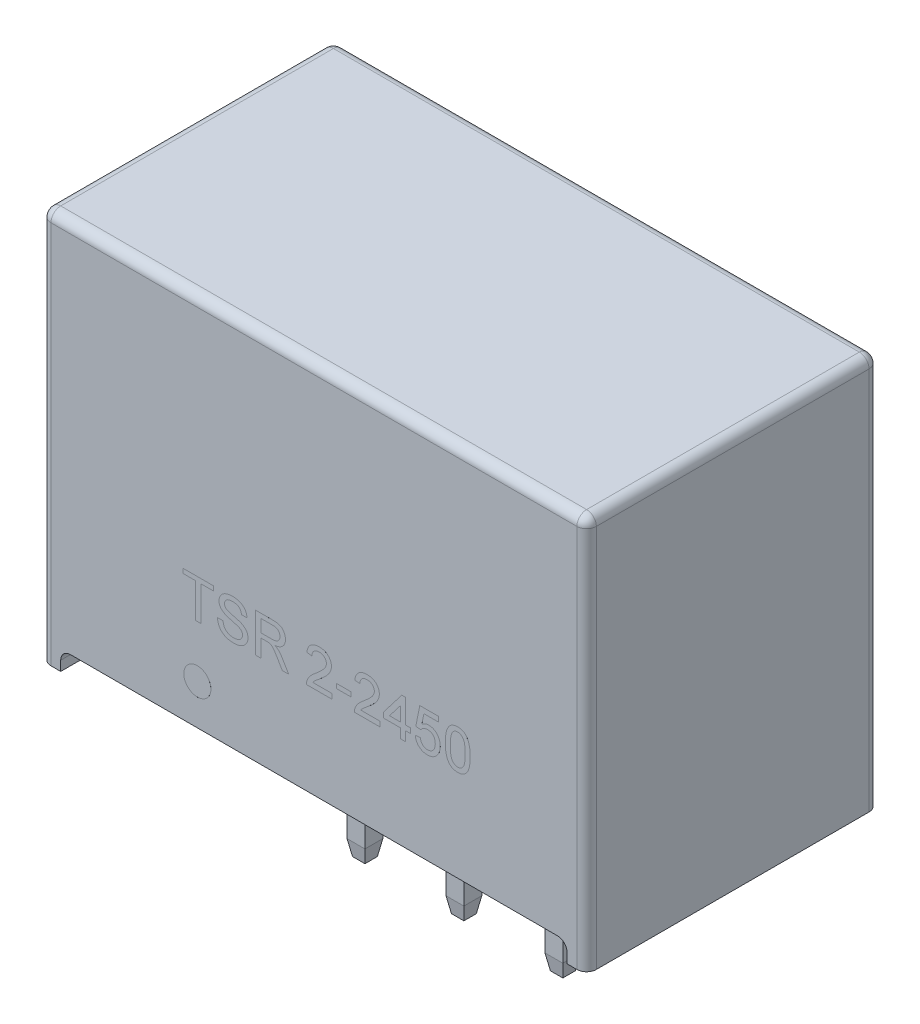
from build123d import *

# Parameters (mm, degrees)
SKETCH2_W              = 14
SKETCH2_H              = 7.5
BOSS_EXTRUDE1_DEPTH    = 10.1
SKETCH3_W              = 13
SKETCH3_H              = 7.5
CUT_EXTRUDE1_DEPTH     = 0.5
SKETCH5_R              = 0.348019795
SKETCH5_W              = 0.371794871
SKETCH5_H              = 0.115384615
BOSS_EXTRUDE4_DEPTH    = 0.0001
SKETCH4_W              = 0.46
SKETCH4_H              = 0.46
BOSS_EXTRUDE3_DEPTH    = 4.6
FILLET1_R              = 0.25
FILLET2_R              = 0.25
CHAMFER2_SIZE          = 0.4
CHAMFER2_SIZE2         = 0.070530792
CHAMFER2_PART_2_SIZE   = 0.4
CHAMFER2_PART_2_SIZE2  = 0.070530792
CHAMFER2_PART_3_SIZE   = 0.4
CHAMFER2_PART_3_SIZE2  = 0.070530792
CHAMFER2_PART_4_SIZE   = 0.4
CHAMFER2_PART_4_SIZE2  = 0.070530792
CHAMFER2_PART_5_SIZE   = 0.4
CHAMFER2_PART_5_SIZE2  = 0.070530792
CHAMFER2_PART_6_SIZE   = 0.4
CHAMFER2_PART_6_SIZE2  = 0.070530792
CHAMFER2_PART_7_SIZE   = 0.4
CHAMFER2_PART_7_SIZE2  = 0.070530792
CHAMFER2_PART_8_SIZE   = 0.4
CHAMFER2_PART_8_SIZE2  = 0.070530792
CHAMFER2_PART_9_SIZE   = 0.4
CHAMFER2_PART_9_SIZE2  = 0.070530792
CHAMFER2_PART_10_SIZE  = 0.4
CHAMFER2_PART_10_SIZE2 = 0.070530792
CHAMFER2_PART_11_SIZE  = 0.4
CHAMFER2_PART_11_SIZE2 = 0.070530792
CHAMFER2_PART_12_SIZE  = 0.4
CHAMFER2_PART_12_SIZE2 = 0.070530792


with BuildPart() as part:
    # Sketch2 → Boss-Extrude1 (new body)
    with BuildSketch(Plane(origin=(0, 0, 0), x_dir=(1, 0, 0), z_dir=(0, 1, 0))):
        Rectangle(SKETCH2_W, SKETCH2_H)
    extrude(amount=BOSS_EXTRUDE1_DEPTH)

    # Sketch3 → Cut-Extrude1 (cut)
    with BuildSketch(Plane.XZ):
        Rectangle(SKETCH3_W, SKETCH3_H)
    extrude(amount=-CUT_EXTRUDE1_DEPTH, mode=Mode.SUBTRACT)

    # Sketch5 → Boss-Extrude4 (add)
    with BuildSketch(Plane.XY.offset(3.75)):
        with Locations((-2.991998919, 1.533519028)):
            Circle(SKETCH5_R)
        Polygon((-3.038553538, 2.864581875), (-3.038553538, 3.74919726), (-3.359066358, 3.74919726), (-3.359066358, 3.864581875), (-2.577015076, 3.864581875), (-2.577015076, 3.74919726), (-2.897527897, 3.74919726), (-2.897527897, 2.864581875), align=None)
        with BuildLine():
            Line((-2.474450974, 3.210735721), (-2.333425333, 3.210735721))
            add(Edge.make_bspline(
                [(-2.333425333, 3.210735721), (-2.331874133, 3.198073558), (-2.328894193, 3.17374886), (-2.320561986, 3.139272263), (-2.309837897, 3.108274264), (-2.296475978, 3.080343465), (-2.278898883, 3.055814755), (-2.257721506, 3.033690232), (-2.232002735, 3.014531735), (-2.202972106, 2.997481929), (-2.170640086, 2.984095134), (-2.136122771, 2.974171282), (-2.099584779, 2.968291321), (-2.074565811, 2.967533125), (-2.061790717, 2.967145978)],
                knots=[0, 0, 0, 0, 3.8245e-05, 7.3471e-05, 0.000106162, 0.000136532, 0.00016599, 0.000196308, 0.000228039, 0.000261882, 0.000297077, 0.00033271, 0.00036943, 0.000407744, 0.000407744, 0.000407744, 0.000407744], degree=3))
            add(Edge.make_bspline(
                [(-2.061790717, 2.967145978), (-2.05048586, 2.967355218), (-2.028443576, 2.967763198), (-1.996556949, 2.972664039), (-1.966551541, 2.97961575), (-1.938985782, 2.990131301), (-1.913961362, 3.002900478), (-1.892230456, 3.018345096), (-1.873677764, 3.035762383), (-1.859149662, 3.0556111), (-1.847736675, 3.076409237), (-1.839364069, 3.097787576), (-1.834376679, 3.119627459), (-1.833741156, 3.134322458), (-1.833425333, 3.141625144)],
                knots=[0, 0, 0, 0, 3.3883e-05, 6.6066e-05, 9.6578e-05, 0.000126119, 0.000154342, 0.000180633, 0.000205853, 0.000230332, 0.000254089, 0.000276857, 0.000299019, 0.000320913, 0.000320913, 0.000320913, 0.000320913], degree=3))
            add(Edge.make_bspline(
                [(-1.833425333, 3.141625144), (-1.833762954, 3.148853859), (-1.834422834, 3.162982372), (-1.838723091, 3.183551721), (-1.846896336, 3.20237865), (-1.857502061, 3.220231587), (-1.872256435, 3.23655423), (-1.890896921, 3.25159409), (-1.913834217, 3.265229372), (-1.930953457, 3.272696847), (-1.939995846, 3.27664117)],
                knots=[0, 0, 0, 0, 2.1694e-05, 4.2401e-05, 6.2602e-05, 8.3009e-05, 0.000104436, 0.000128214, 0.000154632, 0.000184209, 0.000184209, 0.000184209, 0.000184209], degree=3))
            add(Edge.make_bspline(
                [(-1.939995846, 3.27664117), (-1.943518894, 3.278086913), (-1.951478099, 3.281353108), (-1.965119805, 3.285676988), (-1.981307415, 3.291268207), (-2.000429826, 3.297026252), (-2.022384666, 3.303117458), (-2.047135383, 3.31001178), (-2.074668146, 3.317343514), (-2.104202079, 3.325147347), (-2.134022351, 3.333082647), (-2.162512137, 3.341025379), (-2.188724095, 3.34908827), (-2.212872935, 3.35685172), (-2.234834161, 3.3646472), (-2.254670101, 3.372261286), (-2.272405488, 3.379539498), (-2.283237587, 3.384891056), (-2.288353217, 3.387418413)],
                knots=[0, 0, 0, 0, 1.142e-05, 2.58e-05, 4.2904e-05, 6.2801e-05, 8.5695e-05, 0.000111258, 0.000139879, 0.00017117, 0.000202901, 0.000232453, 0.000259891, 0.000285167, 0.000308547, 0.000329789, 0.000348912, 0.000366025, 0.000366025, 0.000366025, 0.000366025], degree=3))
            add(Edge.make_bspline(
                [(-2.288353217, 3.387418413), (-2.300122855, 3.393776711), (-2.322841318, 3.406049879), (-2.353417854, 3.427994339), (-2.379181689, 3.452345778), (-2.400024132, 3.479068887), (-2.416357539, 3.507711713), (-2.427377617, 3.53832295), (-2.43492546, 3.570346946), (-2.435630826, 3.592368464), (-2.435989435, 3.603564247)],
                knots=[0, 0, 0, 0, 4.0103e-05, 7.7409e-05, 0.000112548, 0.000146087, 0.000178736, 0.000210998, 0.000243416, 0.000276942, 0.000276942, 0.000276942, 0.000276942], degree=3))
            add(Edge.make_bspline(
                [(-2.435989435, 3.603564247), (-2.435513489, 3.615961686), (-2.434566837, 3.640620101), (-2.426169507, 3.676804789), (-2.412775605, 3.711624084), (-2.397529277, 3.739267633), (-2.382660738, 3.76017156), (-2.370334607, 3.775226187), (-2.356508439, 3.789142165), (-2.341608034, 3.802113753), (-2.325367031, 3.81394714), (-2.308188371, 3.825128663), (-2.289450282, 3.83473945), (-2.263120482, 3.846971813), (-2.227897553, 3.859186972), (-2.18355629, 3.869830933), (-2.136888568, 3.87609894), (-2.105078752, 3.87696176), (-2.088833987, 3.877402388)],
                knots=[0, 0, 0, 0, 3.7151e-05, 7.3892e-05, 0.000110797, 0.000148816, 0.000168214, 0.000187707, 0.000207113, 0.000226994, 0.000246907, 0.000267356, 0.000288414, 0.000310016, 0.00035443, 0.000399956, 0.000446645, 0.000495372, 0.000495372, 0.000495372, 0.000495372], degree=3))
            add(Edge.make_bspline(
                [(-2.088833987, 3.877402388), (-2.071053012, 3.876994964), (-2.036430028, 3.876201631), (-1.986121853, 3.869601247), (-1.939198099, 3.85826665), (-1.902398881, 3.845578706), (-1.875193649, 3.832733884), (-1.855866295, 3.8227112), (-1.837926689, 3.811123152), (-1.821213337, 3.79858307), (-1.805570996, 3.785096683), (-1.791401709, 3.770343194), (-1.778090206, 3.754825964), (-1.762447335, 3.732548084), (-1.745581003, 3.703063436), (-1.730997764, 3.664864903), (-1.720978908, 3.624549488), (-1.71903001, 3.59667841), (-1.718040717, 3.582530593)],
                knots=[0, 0, 0, 0, 5.3331e-05, 0.000103845, 0.000151849, 0.000197974, 0.00022029, 0.000242066, 0.000263238, 0.000284271, 0.000304718, 0.000325117, 0.000345585, 0.000365984, 0.000406708, 0.000447108, 0.00048831, 0.000530786, 0.000530786, 0.000530786, 0.000530786], degree=3))
            Line((-1.718040717, 3.582530593), (-1.859066358, 3.582530593))
            add(Edge.make_bspline(
                [(-1.859066358, 3.582530593), (-1.859962415, 3.589691217), (-1.861715731, 3.603702435), (-1.866065476, 3.623985782), (-1.872162943, 3.642824042), (-1.879304946, 3.660392895), (-1.887962548, 3.676509604), (-1.898054808, 3.691328926), (-1.909704626, 3.704676265), (-1.922612242, 3.716904306), (-1.937170431, 3.727551517), (-1.953304389, 3.736793623), (-1.971041351, 3.744601087), (-1.99036569, 3.750995654), (-2.011281232, 3.755953751), (-2.03383555, 3.759601022), (-2.058019926, 3.761468953), (-2.074675329, 3.76183161), (-2.083225012, 3.762017772)],
                knots=[0, 0, 0, 0, 2.1644e-05, 4.2351e-05, 6.2117e-05, 8.0978e-05, 9.9171e-05, 0.000116896, 0.000134648, 0.000152221, 0.000170131, 0.000188617, 0.000207899, 0.00022817, 0.000249596, 0.00027232, 0.000296642, 0.000322295, 0.000322295, 0.000322295, 0.000322295], degree=3))
            add(Edge.make_bspline(
                [(-2.083225012, 3.762017772), (-2.092112009, 3.761950786), (-2.10931505, 3.761821118), (-2.134183996, 3.759457425), (-2.157234295, 3.756214355), (-2.178426355, 3.751430551), (-2.197690753, 3.745168535), (-2.215313401, 3.737937343), (-2.230801111, 3.728773535), (-2.244514927, 3.718566244), (-2.25634483, 3.707272441), (-2.266540455, 3.695371503), (-2.275557697, 3.683213089), (-2.282564293, 3.67013261), (-2.288268716, 3.656625446), (-2.291948695, 3.642437705), (-2.294554206, 3.627831824), (-2.294825378, 3.617865939), (-2.294963794, 3.61277899)],
                knots=[0, 0, 0, 0, 2.6649e-05, 5.1587e-05, 7.4874e-05, 9.645e-05, 0.000116659, 0.000135597, 0.000153463, 0.00017049, 0.000186785, 0.000202407, 0.000217474, 0.000232087, 0.000246818, 0.000261348, 0.00027597, 0.000291215, 0.000291215, 0.000291215, 0.000291215], degree=3))
            add(Edge.make_bspline(
                [(-2.294963794, 3.61277899), (-2.294599351, 3.60417543), (-2.293892, 3.587476712), (-2.28666891, 3.563752868), (-2.275559748, 3.542127048), (-2.264615454, 3.530360549), (-2.259106422, 3.524437644)],
                knots=[0, 0, 0, 0, 2.5736e-05, 4.995e-05, 7.3788e-05, 9.795e-05, 9.795e-05, 9.795e-05, 9.795e-05], degree=3))
            add(Edge.make_bspline(
                [(-2.259106422, 3.524437644), (-2.255633588, 3.52147766), (-2.247953628, 3.514931837), (-2.23366388, 3.506269208), (-2.215946711, 3.497516725), (-2.194683738, 3.488816079), (-2.169911546, 3.480061646), (-2.141670091, 3.471047881), (-2.109851807, 3.462095527), (-2.075426353, 3.453468452), (-2.040648618, 3.444806696), (-2.007598078, 3.436177953), (-1.977252087, 3.428000278), (-1.949658793, 3.420024297), (-1.924789634, 3.41227256), (-1.902731041, 3.404582661), (-1.883304551, 3.397509905), (-1.871403531, 3.392533643), (-1.865877256, 3.390222901)],
                knots=[0, 0, 0, 0, 1.3672e-05, 3.0234e-05, 4.9943e-05, 7.2934e-05, 9.9102e-05, 0.000128751, 0.000161853, 0.000198244, 0.000235217, 0.000269374, 0.000300717, 0.000329499, 0.000355539, 0.000378852, 0.000399578, 0.000417545, 0.000417545, 0.000417545, 0.000417545], degree=3))
            add(Edge.make_bspline(
                [(-1.865877256, 3.390222901), (-1.858687291, 3.386907865), (-1.844574596, 3.380401007), (-1.824582073, 3.369291524), (-1.805926881, 3.357754924), (-1.78875974, 3.345480604), (-1.77313616, 3.332442743), (-1.758881451, 3.318790727), (-1.74590952, 3.304601284), (-1.734743784, 3.289420267), (-1.724718098, 3.273861362), (-1.715944955, 3.257707114), (-1.708880989, 3.240862522), (-1.70268545, 3.223530633), (-1.69822908, 3.205518664), (-1.694734388, 3.18700855), (-1.692695992, 3.167913287), (-1.692499312, 3.154984584), (-1.692399692, 3.148436042)],
                knots=[0, 0, 0, 0, 2.3745e-05, 4.6607e-05, 6.8562e-05, 8.9521e-05, 0.00010986, 0.000129553, 0.000148702, 0.000167452, 0.000186011, 0.000204205, 0.000222512, 0.000240758, 0.000259366, 0.000278108, 0.000297243, 0.000316884, 0.000316884, 0.000316884, 0.000316884], degree=3))
            add(Edge.make_bspline(
                [(-1.692399692, 3.148436042), (-1.692921573, 3.135366931), (-1.69395768, 3.109420403), (-1.702878938, 3.07117402), (-1.716893763, 3.034113488), (-1.733329616, 3.004703915), (-1.748866465, 2.982239275), (-1.761918151, 2.966092719), (-1.776391721, 2.951162767), (-1.791930849, 2.936981692), (-1.808656183, 2.923838835), (-1.826708728, 2.911729721), (-1.845897946, 2.900528294), (-1.873299668, 2.886878699), (-1.909693707, 2.872599927), (-1.956052406, 2.86070905), (-2.00490886, 2.852995143), (-2.038456717, 2.852178306), (-2.055580781, 2.851761362)],
                knots=[0, 0, 0, 0, 3.9163e-05, 7.7752e-05, 0.000117188, 0.000157717, 0.000178444, 0.000199092, 0.000219919, 0.000240765, 0.000262164, 0.000283666, 0.000305929, 0.000328774, 0.000375459, 0.000422881, 0.00047212, 0.000523458, 0.000523458, 0.000523458, 0.000523458], degree=3))
            add(Edge.make_bspline(
                [(-2.055580781, 2.851761362), (-2.066468617, 2.851851214), (-2.087796332, 2.85202722), (-2.119135026, 2.854158708), (-2.14916747, 2.857242011), (-2.17786419, 2.861834625), (-2.205135197, 2.867859885), (-2.23107838, 2.875095058), (-2.255755234, 2.883427852), (-2.279079535, 2.893227072), (-2.300990398, 2.904612696), (-2.321881803, 2.916894904), (-2.341412265, 2.930817362), (-2.359622898, 2.946161299), (-2.376975121, 2.962483445), (-2.392749737, 2.98045038), (-2.407483041, 2.999536689), (-2.420838382, 3.019917055), (-2.432769346, 3.041324835), (-2.443498682, 3.063400511), (-2.452538298, 3.086304222), (-2.459823368, 3.109920215), (-2.465994191, 3.13409045), (-2.470273515, 3.159016587), (-2.473419817, 3.184620366), (-2.474105225, 3.201979185), (-2.474450974, 3.210735721)],
                knots=[0, 0, 0, 0, 3.2658e-05, 6.3972e-05, 9.419e-05, 0.000123204, 0.000151103, 0.000177932, 0.000203968, 0.000229193, 0.000253741, 0.000277996, 0.000301842, 0.000325592, 0.000349396, 0.000373235, 0.000397235, 0.000421681, 0.000446255, 0.000470715, 0.000495266, 0.000520039, 0.000544817, 0.000570045, 0.000595861, 0.000622141, 0.000622141, 0.000622141, 0.000622141], degree=3))
        make_face()
        with BuildLine():
            Line((-1.500091999, 2.864581875), (-1.500091999, 3.864581875))
            Line((-1.500091999, 3.864581875), (-1.066197769, 3.864581875))
            add(Edge.make_bspline(
                [(-1.066197769, 3.864581875), (-1.055980888, 3.864501822), (-1.036207312, 3.864346887), (-1.007531543, 3.86325013), (-0.980765588, 3.860885807), (-0.955860232, 3.858329122), (-0.932819901, 3.854404952), (-0.911668365, 3.849904018), (-0.892372966, 3.844547838), (-0.874847444, 3.838221777), (-0.85858758, 3.831064786), (-0.843515915, 3.822234215), (-0.829005938, 3.812557792), (-0.815596166, 3.80118944), (-0.802932914, 3.788742145), (-0.791027919, 3.775046778), (-0.780057425, 3.759984488), (-0.766526634, 3.738427229), (-0.752010855, 3.709717499), (-0.73991693, 3.672975265), (-0.732118984, 3.634541547), (-0.731284582, 3.608276554), (-0.73086123, 3.594950465)],
                knots=[0, 0, 0, 0, 3.0652e-05, 5.9323e-05, 8.6056e-05, 0.000111253, 0.000134404, 0.000156133, 0.000176109, 0.000194422, 0.000211996, 0.000229314, 0.00024676, 0.000264252, 0.000281959, 0.000299993, 0.000318624, 0.000337798, 0.00037632, 0.000414772, 0.000453548, 0.000493484, 0.000493484, 0.000493484, 0.000493484], degree=3))
            add(Edge.make_bspline(
                [(-0.73086123, 3.594950465), (-0.731056913, 3.586396304), (-0.731443399, 3.56950125), (-0.734403926, 3.544660998), (-0.739760759, 3.520927137), (-0.746629842, 3.498091808), (-0.756031521, 3.476478553), (-0.766922957, 3.455645914), (-0.780415899, 3.436166219), (-0.79552274, 3.417520755), (-0.812846234, 3.400108858), (-0.832538778, 3.384558707), (-0.854405163, 3.370571314), (-0.878548371, 3.358532599), (-0.904690489, 3.347528641), (-0.93315953, 3.338667725), (-0.963840594, 3.331432106), (-0.985110134, 3.327928341), (-0.996085589, 3.326120337)],
                knots=[0, 0, 0, 0, 2.5661e-05, 5.0681e-05, 7.4886e-05, 9.8583e-05, 0.000122099, 0.000145489, 0.000168992, 0.000193051, 0.000217414, 0.000242505, 0.000268178, 0.000295144, 0.000323343, 0.000353183, 0.000384474, 0.000417836, 0.000417836, 0.000417836, 0.000417836], degree=3))
            add(Edge.make_bspline(
                [(-0.996085589, 3.326120337), (-0.988034677, 3.322053193), (-0.972745704, 3.314329542), (-0.951577932, 3.302218923), (-0.933634745, 3.289844855), (-0.923239347, 3.280994558), (-0.91836123, 3.27684149)],
                knots=[0, 0, 0, 0, 2.7057e-05, 5.1383e-05, 7.3111e-05, 9.2322e-05, 9.2322e-05, 9.2322e-05, 9.2322e-05], degree=3))
            add(Edge.make_bspline(
                [(-0.91836123, 3.27684149), (-0.908914481, 3.267580916), (-0.889510187, 3.248559037), (-0.862770227, 3.216159206), (-0.836844918, 3.180093222), (-0.821093338, 3.154028213), (-0.81299264, 3.140623542)],
                knots=[0, 0, 0, 0, 3.9662e-05, 8.1469e-05, 0.000125831, 0.0001728, 0.0001728, 0.0001728, 0.0001728], degree=3))
            Line((-0.81299264, 3.140623542), (-0.64893014, 2.864581875))
            Line((-0.64893014, 2.864581875), (-0.810588794, 2.864581875))
            Line((-0.810588794, 2.864581875), (-0.935188153, 3.075719696))
            add(Edge.make_bspline(
                [(-0.935188153, 3.075719696), (-0.93966812, 3.08312772), (-0.948349561, 3.097483254), (-0.960889591, 3.118448821), (-0.973184678, 3.137750967), (-0.984588161, 3.155941355), (-0.995562812, 3.17268975), (-1.006002591, 3.188054332), (-1.01562019, 3.202236664), (-1.02753283, 3.218748589), (-1.041397164, 3.237019188), (-1.05757589, 3.255834454), (-1.072982835, 3.270835615), (-1.091956772, 3.28554585), (-1.115458862, 3.299304801), (-1.135436083, 3.305626661), (-1.145124051, 3.308692452)],
                knots=[0, 0, 0, 0, 2.5972e-05, 5.033e-05, 7.3284e-05, 9.4624e-05, 0.000114737, 0.00013335, 0.000150352, 0.000166141, 0.000194428, 0.000219133, 0.000240526, 0.000258798, 0.000291099, 0.000321512, 0.000321512, 0.000321512, 0.000321512], degree=3))
            add(Edge.make_bspline(
                [(-1.145124051, 3.308692452), (-1.149188763, 3.309425458), (-1.158468622, 3.311098932), (-1.1742258, 3.31219188), (-1.193317555, 3.313351899), (-1.207153674, 3.3133181), (-1.214635269, 3.313299824)],
                knots=[0, 0, 0, 0, 1.2383e-05, 2.827e-05, 4.7327e-05, 6.9764e-05, 6.9764e-05, 6.9764e-05, 6.9764e-05], degree=3))
            Line((-1.214635269, 3.313299824), (-1.359066358, 3.313299824))
            Line((-1.359066358, 3.313299824), (-1.359066358, 2.864581875))
            Line((-1.359066358, 2.864581875), (-1.500091999, 2.864581875))
        make_face()
        with BuildLine():
            Line((-1.359066358, 3.428684439), (-1.091237833, 3.428684439))
            add(Edge.make_bspline(
                [(-1.091237833, 3.428684439), (-1.077807896, 3.428894563), (-1.052701889, 3.429287371), (-1.01759511, 3.432641532), (-0.987676322, 3.437971437), (-0.962354076, 3.445745727), (-0.941079391, 3.456539024), (-0.922576394, 3.469692673), (-0.90720017, 3.486168988), (-0.894408741, 3.504759002), (-0.8844657, 3.525216384), (-0.877293265, 3.546703864), (-0.872598781, 3.569040854), (-0.872126276, 3.584243101), (-0.871886871, 3.591945657)],
                knots=[0, 0, 0, 0, 4.0282e-05, 7.5304e-05, 0.000105674, 0.000131332, 0.000154445, 0.000176964, 0.000199068, 0.000221683, 0.000244439, 0.000267054, 0.000289525, 0.000312605, 0.000312605, 0.000312605, 0.000312605], degree=3))
            add(Edge.make_bspline(
                [(-0.871886871, 3.591945657), (-0.872072999, 3.597558803), (-0.872437568, 3.608553306), (-0.874348758, 3.624690184), (-0.878064567, 3.640023949), (-0.882971284, 3.654635655), (-0.889527653, 3.668418283), (-0.897316351, 3.681478633), (-0.906610673, 3.693744319), (-0.917256784, 3.705252704), (-0.929480455, 3.71572421), (-0.94344276, 3.724758848), (-0.95903358, 3.732436341), (-0.976271037, 3.738529714), (-0.99510083, 3.743403419), (-1.015630152, 3.746645739), (-1.037765119, 3.74899187), (-1.053103367, 3.749127517), (-1.060989435, 3.74919726)],
                knots=[0, 0, 0, 0, 1.6846e-05, 3.2996e-05, 4.8642e-05, 6.4099e-05, 7.9154e-05, 9.4339e-05, 0.000109643, 0.000125235, 0.000141292, 0.000157793, 0.000174994, 0.000193307, 0.000212547, 0.000233261, 0.000255606, 0.000279251, 0.000279251, 0.000279251, 0.000279251], degree=3))
            Line((-1.060989435, 3.74919726), (-1.359066358, 3.74919726))
            Line((-1.359066358, 3.74919726), (-1.359066358, 3.428684439))
        make_face(mode=Mode.SUBTRACT)
        with BuildLine():
            Line((0.461446462, 2.992787003), (0.461446462, 2.864581875))
            Line((0.461446462, 2.864581875), (-0.192399692, 2.864581875))
            add(Edge.make_bspline(
                [(-0.192399692, 2.864581875), (-0.192413078, 2.872201466), (-0.192439805, 2.887415109), (-0.189865411, 2.909915123), (-0.185833396, 2.932116654), (-0.181274397, 2.946353614), (-0.178978217, 2.953524183)],
                knots=[0, 0, 0, 0, 2.284e-05, 4.5604e-05, 6.784e-05, 9.0404e-05, 9.0404e-05, 9.0404e-05, 9.0404e-05], degree=3))
            add(Edge.make_bspline(
                [(-0.178978217, 2.953524183), (-0.174735642, 2.965240037), (-0.166097059, 2.989095445), (-0.148595199, 3.023515468), (-0.128008876, 3.057727326), (-0.107965193, 3.085580608), (-0.089609507, 3.107833433), (-0.074215872, 3.125243694), (-0.057156903, 3.143065147), (-0.03844626, 3.161294538), (-0.018264024, 3.18004993), (0.003417345, 3.199393873), (0.02685387, 3.218965871), (0.043215018, 3.231939005), (0.051590693, 3.238580272)],
                knots=[0, 0, 0, 0, 3.7351e-05, 7.6052e-05, 0.000115594, 0.000157068, 0.000178844, 0.000202118, 0.000226771, 0.000252836, 0.000280475, 0.000309421, 0.000339994, 0.000372061, 0.000372061, 0.000372061, 0.000372061], degree=3))
            add(Edge.make_bspline(
                [(0.051590693, 3.238580272), (0.064457799, 3.249410307), (0.089234227, 3.270264224), (0.124222427, 3.301209505), (0.156178452, 3.329943952), (0.18459344, 3.356971193), (0.209699794, 3.382029083), (0.231556465, 3.405060849), (0.250351515, 3.425994614), (0.265855493, 3.445588092), (0.278936675, 3.464089785), (0.290021821, 3.482137044), (0.29925982, 3.500045115), (0.306953836, 3.517757332), (0.31303915, 3.53534944), (0.317187157, 3.552872694), (0.320000191, 3.570153219), (0.320281638, 3.581651872), (0.320420821, 3.587338285)],
                knots=[0, 0, 0, 0, 5.0453e-05, 9.715e-05, 0.000140121, 0.00017937, 0.000214782, 0.000246523, 0.000274621, 0.000299148, 0.000321434, 0.000342563, 0.000362632, 0.000381834, 0.000400458, 0.000418387, 0.00043581, 0.000452856, 0.000452856, 0.000452856, 0.000452856], degree=3))
            add(Edge.make_bspline(
                [(0.320420821, 3.587338285), (0.320281621, 3.59295835), (0.320008518, 3.603984613), (0.317417331, 3.620121478), (0.313810192, 3.635661666), (0.307978544, 3.650325417), (0.301037129, 3.664546983), (0.292133088, 3.677876981), (0.281832943, 3.690647627), (0.270040148, 3.702522221), (0.257159655, 3.713662486), (0.24276754, 3.722922752), (0.227809072, 3.731259751), (0.211768198, 3.737963176), (0.194670982, 3.742885621), (0.176641885, 3.746458048), (0.157683767, 3.748723159), (0.144746185, 3.74903683), (0.138129154, 3.74919726)],
                knots=[0, 0, 0, 0, 1.6846e-05, 3.3051e-05, 4.8938e-05, 6.46e-05, 8.0278e-05, 9.6335e-05, 0.000112572, 0.000129429, 0.000146485, 0.000163542, 0.000180664, 0.000197815, 0.000215563, 0.000233949, 0.000252908, 0.000272756, 0.000272756, 0.000272756, 0.000272756], degree=3))
            add(Edge.make_bspline(
                [(0.138129154, 3.74919726), (0.131178148, 3.749037624), (0.117574517, 3.748725207), (0.097689653, 3.746451063), (0.078812421, 3.742976478), (0.060987878, 3.737664136), (0.044237719, 3.730971889), (0.028630165, 3.722548132), (0.013915272, 3.713039234), (0.00055647, 3.701781417), (-0.011523719, 3.689298794), (-0.022248115, 3.675708993), (-0.031035146, 3.66074976), (-0.038291839, 3.644750014), (-0.044126827, 3.627659459), (-0.04836283, 3.60934744), (-0.050672327, 3.589866832), (-0.051136748, 3.576526516), (-0.051374051, 3.56971008)],
                knots=[0, 0, 0, 0, 2.0849e-05, 4.0803e-05, 5.9975e-05, 7.8356e-05, 9.6509e-05, 0.000113984, 0.000131486, 0.000148978, 0.000166261, 0.000183532, 0.000200778, 0.000218169, 0.00023616, 0.000254868, 0.000274448, 0.000294905, 0.000294905, 0.000294905, 0.000294905], degree=3))
            Line((-0.051374051, 3.56971008), (-0.179579179, 3.582530593))
            add(Edge.make_bspline(
                [(-0.179579179, 3.582530593), (-0.178267458, 3.593703983), (-0.175715619, 3.615440852), (-0.169359335, 3.646923045), (-0.160435687, 3.676210509), (-0.14975779, 3.703711573), (-0.136372039, 3.728958085), (-0.1212406, 3.752472242), (-0.103393766, 3.773508272), (-0.083677749, 3.792729262), (-0.06187654, 3.809668012), (-0.038194925, 3.824466362), (-0.012643739, 3.836844268), (0.014634707, 3.847092658), (0.043703039, 3.85486837), (0.074520135, 3.860444288), (0.107135552, 3.863881348), (0.129506864, 3.864345034), (0.140933642, 3.864581875)],
                knots=[0, 0, 0, 0, 3.3743e-05, 6.5643e-05, 9.6189e-05, 0.000125502, 0.000153995, 0.000181776, 0.00020922, 0.000236561, 0.00026425, 0.000291876, 0.000320186, 0.000349282, 0.000379168, 0.000410326, 0.000443155, 0.000477431, 0.000477431, 0.000477431, 0.000477431], degree=3))
            add(Edge.make_bspline(
                [(0.140933642, 3.864581875), (0.152497191, 3.864383862), (0.175023053, 3.863998133), (0.207846856, 3.860051342), (0.23881702, 3.853904251), (0.268047083, 3.845337089), (0.295364348, 3.834102984), (0.32078983, 3.820377445), (0.344440759, 3.804294359), (0.365921978, 3.785660662), (0.385292154, 3.765318859), (0.402267257, 3.74360977), (0.416459261, 3.720626137), (0.428542871, 3.696681243), (0.43750573, 3.671269147), (0.443808578, 3.644735332), (0.448091546, 3.617057124), (0.448445447, 3.59817222), (0.448625949, 3.588540208)],
                knots=[0, 0, 0, 0, 3.4676e-05, 6.755e-05, 9.9018e-05, 0.000129315, 0.000158777, 0.000187459, 0.000215851, 0.000244402, 0.000272599, 0.000300007, 0.00032691, 0.000353517, 0.000380319, 0.000407527, 0.000435262, 0.000464133, 0.000464133, 0.000464133, 0.000464133], degree=3))
            add(Edge.make_bspline(
                [(0.448625949, 3.588540208), (0.448350325, 3.578644408), (0.447798467, 3.558830969), (0.443491146, 3.529215721), (0.436121271, 3.499921865), (0.426350784, 3.470592876), (0.413002265, 3.441112349), (0.396138678, 3.4110736), (0.375217555, 3.380365667), (0.355097301, 3.354260513), (0.336368611, 3.33237781), (0.319767396, 3.314367068), (0.300560752, 3.295231858), (0.27946919, 3.274309485), (0.255632497, 3.252342527), (0.229735555, 3.228673171), (0.201211469, 3.203924304), (0.181410194, 3.187017066), (0.171182039, 3.178283798)],
                knots=[0, 0, 0, 0, 2.9681e-05, 5.9427e-05, 8.9549e-05, 0.00012021, 0.000152041, 0.00018648, 0.000223427, 0.000263415, 0.000285295, 0.00030982, 0.000336875, 0.000366622, 0.000398938, 0.000434108, 0.000471872, 0.000512221, 0.000512221, 0.000512221, 0.000512221], degree=3))
            add(Edge.make_bspline(
                [(0.171182039, 3.178283798), (0.162423169, 3.171153144), (0.145721353, 3.157556085), (0.121959783, 3.137844065), (0.100676644, 3.119768676), (0.081374233, 3.103919503), (0.06475553, 3.089529943), (0.050235166, 3.077230195), (0.038340673, 3.066401832), (0.020227466, 3.049953331), (-0.002714457, 3.026507654), (-0.019619046, 3.003726145), (-0.02773623, 2.992787003)],
                knots=[0, 0, 0, 0, 3.3883e-05, 6.461e-05, 9.2618e-05, 0.000117651, 0.000139531, 0.000158565, 0.000174735, 0.000187779, 0.000231981, 0.000272812, 0.000272812, 0.000272812, 0.000272812], degree=3))
            Line((-0.02773623, 2.992787003), (0.461446462, 2.992787003))
        make_face()
        with Locations((0.762728514, 3.217145978)):
            Rectangle(SKETCH5_W, SKETCH5_H)
        with BuildLine():
            Line((1.692215693, 2.992787003), (1.692215693, 2.864581875))
            Line((1.692215693, 2.864581875), (1.038369539, 2.864581875))
            add(Edge.make_bspline(
                [(1.038369539, 2.864581875), (1.038356153, 2.872201466), (1.038329426, 2.887415109), (1.04090382, 2.909915123), (1.044935835, 2.932116654), (1.049494834, 2.946353614), (1.051791013, 2.953524183)],
                knots=[0, 0, 0, 0, 2.284e-05, 4.5604e-05, 6.784e-05, 9.0404e-05, 9.0404e-05, 9.0404e-05, 9.0404e-05], degree=3))
            add(Edge.make_bspline(
                [(1.051791013, 2.953524183), (1.056033589, 2.965240037), (1.064672172, 2.989095445), (1.082174032, 3.023515468), (1.102760355, 3.057727326), (1.122804038, 3.085580608), (1.141159724, 3.107833433), (1.156553359, 3.125243694), (1.173612328, 3.143065147), (1.19232297, 3.161294538), (1.212505207, 3.18004993), (1.234186576, 3.199393873), (1.257623101, 3.218965871), (1.273984249, 3.231939005), (1.282359924, 3.238580272)],
                knots=[0, 0, 0, 0, 3.7351e-05, 7.6052e-05, 0.000115594, 0.000157068, 0.000178844, 0.000202118, 0.000226771, 0.000252836, 0.000280475, 0.000309421, 0.000339994, 0.000372061, 0.000372061, 0.000372061, 0.000372061], degree=3))
            add(Edge.make_bspline(
                [(1.282359924, 3.238580272), (1.29522703, 3.249410307), (1.320003458, 3.270264224), (1.354991658, 3.301209505), (1.386947683, 3.329943952), (1.41536267, 3.356971193), (1.440469025, 3.382029083), (1.462325696, 3.405060849), (1.481120746, 3.425994614), (1.496624724, 3.445588092), (1.509705906, 3.464089785), (1.520791052, 3.482137044), (1.53002905, 3.500045115), (1.537723067, 3.517757332), (1.543808381, 3.53534944), (1.547956387, 3.552872694), (1.550769422, 3.570153219), (1.551050869, 3.581651872), (1.551190052, 3.587338285)],
                knots=[0, 0, 0, 0, 5.0453e-05, 9.715e-05, 0.000140121, 0.00017937, 0.000214782, 0.000246523, 0.000274621, 0.000299148, 0.000321434, 0.000342563, 0.000362632, 0.000381834, 0.000400458, 0.000418387, 0.00043581, 0.000452856, 0.000452856, 0.000452856, 0.000452856], degree=3))
            add(Edge.make_bspline(
                [(1.551190052, 3.587338285), (1.551050852, 3.59295835), (1.550777749, 3.603984613), (1.548186562, 3.620121478), (1.544579422, 3.635661666), (1.538747775, 3.650325417), (1.53180636, 3.664546983), (1.522902319, 3.677876981), (1.512602173, 3.690647627), (1.500809379, 3.702522221), (1.487928886, 3.713662486), (1.47353677, 3.722922752), (1.458578303, 3.731259751), (1.442537428, 3.737963176), (1.425440213, 3.742885621), (1.407411116, 3.746458048), (1.388452998, 3.748723159), (1.375515416, 3.74903683), (1.368898385, 3.74919726)],
                knots=[0, 0, 0, 0, 1.6846e-05, 3.3051e-05, 4.8938e-05, 6.46e-05, 8.0278e-05, 9.6335e-05, 0.000112572, 0.000129429, 0.000146485, 0.000163542, 0.000180664, 0.000197815, 0.000215563, 0.000233949, 0.000252908, 0.000272756, 0.000272756, 0.000272756, 0.000272756], degree=3))
            add(Edge.make_bspline(
                [(1.368898385, 3.74919726), (1.361947379, 3.749037624), (1.348343748, 3.748725207), (1.328458883, 3.746451063), (1.309581651, 3.742976478), (1.291757109, 3.737664136), (1.27500695, 3.730971889), (1.259399395, 3.722548132), (1.244684503, 3.713039234), (1.231325701, 3.701781417), (1.219245511, 3.689298794), (1.208521115, 3.675708993), (1.199734084, 3.66074976), (1.192477392, 3.644750014), (1.186642404, 3.627659459), (1.182406401, 3.60934744), (1.180096903, 3.589866832), (1.179632483, 3.576526516), (1.17939518, 3.56971008)],
                knots=[0, 0, 0, 0, 2.0849e-05, 4.0803e-05, 5.9975e-05, 7.8356e-05, 9.6509e-05, 0.000113984, 0.000131486, 0.000148978, 0.000166261, 0.000183532, 0.000200778, 0.000218169, 0.00023616, 0.000254868, 0.000274448, 0.000294905, 0.000294905, 0.000294905, 0.000294905], degree=3))
            Line((1.17939518, 3.56971008), (1.051190052, 3.582530593))
            add(Edge.make_bspline(
                [(1.051190052, 3.582530593), (1.052501772, 3.593703983), (1.055053612, 3.615440852), (1.061409896, 3.646923045), (1.070333544, 3.676210509), (1.081011441, 3.703711573), (1.094397192, 3.728958085), (1.109528631, 3.752472242), (1.127375465, 3.773508272), (1.147091481, 3.792729262), (1.168892691, 3.809668012), (1.192574305, 3.824466362), (1.218125491, 3.836844268), (1.245403938, 3.847092658), (1.27447227, 3.85486837), (1.305289365, 3.860444288), (1.337904783, 3.863881348), (1.360276095, 3.864345034), (1.371702872, 3.864581875)],
                knots=[0, 0, 0, 0, 3.3743e-05, 6.5643e-05, 9.6189e-05, 0.000125502, 0.000153995, 0.000181776, 0.00020922, 0.000236561, 0.00026425, 0.000291876, 0.000320186, 0.000349282, 0.000379168, 0.000410326, 0.000443155, 0.000477431, 0.000477431, 0.000477431, 0.000477431], degree=3))
            add(Edge.make_bspline(
                [(1.371702872, 3.864581875), (1.383266422, 3.864383862), (1.405792284, 3.863998133), (1.438616086, 3.860051342), (1.469586251, 3.853904251), (1.498816313, 3.845337089), (1.526133579, 3.834102984), (1.551559061, 3.820377445), (1.57520999, 3.804294359), (1.596691208, 3.785660662), (1.616061385, 3.765318859), (1.633036488, 3.74360977), (1.647228492, 3.720626137), (1.659312101, 3.696681243), (1.668274961, 3.671269147), (1.674577809, 3.644735332), (1.678860777, 3.617057124), (1.679214677, 3.59817222), (1.67939518, 3.588540208)],
                knots=[0, 0, 0, 0, 3.4676e-05, 6.755e-05, 9.9018e-05, 0.000129315, 0.000158777, 0.000187459, 0.000215851, 0.000244402, 0.000272599, 0.000300007, 0.00032691, 0.000353517, 0.000380319, 0.000407527, 0.000435262, 0.000464133, 0.000464133, 0.000464133, 0.000464133], degree=3))
            add(Edge.make_bspline(
                [(1.67939518, 3.588540208), (1.679119555, 3.578644408), (1.678567698, 3.558830969), (1.674260377, 3.529215721), (1.666890502, 3.499921865), (1.657120015, 3.470592876), (1.643771496, 3.441112349), (1.626907909, 3.4110736), (1.605986786, 3.380365667), (1.585866532, 3.354260513), (1.567137841, 3.33237781), (1.550536627, 3.314367068), (1.531329982, 3.295231858), (1.510238421, 3.274309485), (1.486401728, 3.252342527), (1.460504786, 3.228673171), (1.4319807, 3.203924304), (1.412179425, 3.187017066), (1.40195127, 3.178283798)],
                knots=[0, 0, 0, 0, 2.9681e-05, 5.9427e-05, 8.9549e-05, 0.00012021, 0.000152041, 0.00018648, 0.000223427, 0.000263415, 0.000285295, 0.00030982, 0.000336875, 0.000366622, 0.000398938, 0.000434108, 0.000471872, 0.000512221, 0.000512221, 0.000512221, 0.000512221], degree=3))
            add(Edge.make_bspline(
                [(1.40195127, 3.178283798), (1.3931924, 3.171153144), (1.376490584, 3.157556085), (1.352729014, 3.137844065), (1.331445875, 3.119768676), (1.312143463, 3.103919503), (1.295524761, 3.089529943), (1.281004397, 3.077230195), (1.269109904, 3.066401832), (1.250996696, 3.049953331), (1.228054774, 3.026507654), (1.211150185, 3.003726145), (1.203033001, 2.992787003)],
                knots=[0, 0, 0, 0, 3.3883e-05, 6.461e-05, 9.2618e-05, 0.000117651, 0.000139531, 0.000158565, 0.000174735, 0.000187779, 0.000231981, 0.000272812, 0.000272812, 0.000272812, 0.000272812], degree=3))
            Line((1.203033001, 2.992787003), (1.692215693, 2.992787003))
        make_face()
        Polygon((2.217856719, 2.864581875), (2.217856719, 3.108171619), (1.781959283, 3.108171619), (1.781959283, 3.236376747), (2.256318257, 3.851761362), (2.346061847, 3.851761362), (2.346061847, 3.236376747), (2.474266975, 3.236376747), (2.474266975, 3.108171619), (2.346061847, 3.108171619), (2.346061847, 2.864581875), align=None)
        Polygon((2.217856719, 3.236376747), (2.217856719, 3.596553029), (1.940212488, 3.236376747), align=None, mode=Mode.SUBTRACT)
        with BuildLine():
            Line((2.602472103, 3.133812644), (2.730677231, 3.146633157))
            add(Edge.make_bspline(
                [(2.730677231, 3.146633157), (2.731946663, 3.139409502), (2.734415906, 3.125358369), (2.739121321, 3.105018937), (2.745232316, 3.086123036), (2.752098691, 3.068507017), (2.760260536, 3.052357147), (2.769103963, 3.037418429), (2.779532978, 3.024221139), (2.790497687, 3.012075048), (2.802532293, 3.001372194), (2.815752921, 2.992349319), (2.829790706, 2.984477407), (2.844816624, 2.978032235), (2.860853704, 2.973314708), (2.877697836, 2.969583954), (2.895565919, 2.967704045), (2.90775719, 2.967334379), (2.913970501, 2.967145978)],
                knots=[0, 0, 0, 0, 2.2002e-05, 4.2798e-05, 6.2564e-05, 8.1535e-05, 9.9453e-05, 0.000116802, 0.00013351, 0.000149815, 0.000165852, 0.000181689, 0.000197741, 0.000214075, 0.000230615, 0.000247824, 0.000265764, 0.000284411, 0.000284411, 0.000284411, 0.000284411], degree=3))
            add(Edge.make_bspline(
                [(2.913970501, 2.967145978), (2.921592841, 2.967330155), (2.936498659, 2.967690323), (2.958183802, 2.970736478), (2.978667175, 2.975759235), (2.997850769, 2.982788209), (3.015959474, 2.991529571), (3.032392546, 3.002848042), (3.048046006, 3.015571122), (3.06191255, 3.030739475), (3.074535, 3.047252761), (3.085429124, 3.065277715), (3.094600438, 3.084561343), (3.102321681, 3.105099947), (3.108023256, 3.127010858), (3.112217224, 3.150177513), (3.114909585, 3.17461467), (3.115163128, 3.191364225), (3.115292616, 3.199918413)],
                knots=[0, 0, 0, 0, 2.2858e-05, 4.4701e-05, 6.5544e-05, 8.6013e-05, 0.000105901, 0.00012568, 0.000145737, 0.000166288, 0.000187162, 0.000208016, 0.00022934, 0.000251145, 0.000273739, 0.000297157, 0.000321734, 0.000347388, 0.000347388, 0.000347388, 0.000347388], degree=3))
            add(Edge.make_bspline(
                [(3.115292616, 3.199918413), (3.115145443, 3.208070443), (3.114858862, 3.223944336), (3.112445384, 3.247059363), (3.108373563, 3.268794484), (3.103105008, 3.289389257), (3.095842969, 3.308521864), (3.087229782, 3.326469709), (3.076678267, 3.342851886), (3.064939009, 3.358178477), (3.051531295, 3.371918148), (3.036273988, 3.38351956), (3.019765623, 3.393673138), (3.001673706, 3.401907057), (2.981987582, 3.408024549), (2.960902878, 3.412731409), (2.938200809, 3.415207024), (2.922589412, 3.415641025), (2.914571462, 3.415863926)],
                knots=[0, 0, 0, 0, 2.4452e-05, 4.7614e-05, 6.9617e-05, 9.0753e-05, 0.000111292, 0.000130912, 0.000150362, 0.000169636, 0.000188759, 0.000207751, 0.00022699, 0.000246802, 0.000267201, 0.000288734, 0.000311519, 0.000335578, 0.000335578, 0.000335578, 0.000335578], degree=3))
            add(Edge.make_bspline(
                [(2.914571462, 3.415863926), (2.904601531, 3.415572286), (2.885481459, 3.415012987), (2.858007881, 3.410307801), (2.832997689, 3.402707172), (2.810734046, 3.39137936), (2.790842582, 3.377846428), (2.772910061, 3.362533301), (2.756788612, 3.345450332), (2.747945341, 3.33258884), (2.743497744, 3.326120337)],
                knots=[0, 0, 0, 0, 2.9891e-05, 5.7324e-05, 8.3363e-05, 0.000107999, 0.000131946, 0.00015539, 0.000178636, 0.000202156, 0.000202156, 0.000202156, 0.000202156], degree=3))
            Line((2.743497744, 3.326120337), (2.615292616, 3.338940849))
            Line((2.615292616, 3.338940849), (2.717856719, 3.851761362))
            Line((2.717856719, 3.851761362), (3.192215693, 3.851761362))
            Line((3.192215693, 3.851761362), (3.192215693, 3.723556234))
            Line((3.192215693, 3.723556234), (2.822624347, 3.723556234))
            Line((2.822624347, 3.723556234), (2.771742936, 3.464541811))
            add(Edge.make_bspline(
                [(2.771742936, 3.464541811), (2.778816952, 3.469850251), (2.7927092, 3.480275189), (2.814378616, 3.49392527), (2.836357882, 3.505431379), (2.858519052, 3.514853914), (2.88103816, 3.522194052), (2.903779316, 3.527293641), (2.926819949, 3.530740244), (2.942270053, 3.531078626), (2.950028193, 3.531248542)],
                knots=[0, 0, 0, 0, 2.6525e-05, 5.2091e-05, 7.6731e-05, 0.000100878, 0.000124253, 0.000147676, 0.000170737, 0.000193995, 0.000193995, 0.000193995, 0.000193995], degree=3))
            add(Edge.make_bspline(
                [(2.950028193, 3.531248542), (2.960124886, 3.530984), (2.980007723, 3.530463054), (3.009305772, 3.526182826), (3.037319635, 3.518916855), (3.064269051, 3.509130651), (3.08979866, 3.496157366), (3.114167059, 3.480449473), (3.137275864, 3.461877496), (3.158994434, 3.440791849), (3.178694041, 3.417384565), (3.196325833, 3.392419039), (3.210726517, 3.365395531), (3.22283848, 3.337019629), (3.231973583, 3.306825533), (3.238907444, 3.275241757), (3.24261475, 3.241873433), (3.243198806, 3.219157373), (3.243497744, 3.207530593)],
                knots=[0, 0, 0, 0, 3.0281e-05, 5.963e-05, 8.8588e-05, 0.000116981, 0.000145469, 0.000174308, 0.000203809, 0.000234267, 0.000264969, 0.000295477, 0.000325773, 0.000356653, 0.000387891, 0.000420266, 0.000453538, 0.000488422, 0.000488422, 0.000488422, 0.000488422], degree=3))
            add(Edge.make_bspline(
                [(3.243497744, 3.207530593), (3.243270745, 3.196436734), (3.242822356, 3.174523196), (3.239147717, 3.142229548), (3.233094623, 3.111112076), (3.2249912, 3.081078632), (3.214042388, 3.052299783), (3.200762503, 3.02468257), (3.185443412, 2.997938817), (3.173158296, 2.981452837), (3.166975308, 2.973155593)],
                knots=[0, 0, 0, 0, 3.3275e-05, 6.5727e-05, 9.7353e-05, 0.000128311, 0.000158931, 0.000189574, 0.000220186, 0.000251204, 0.000251204, 0.000251204, 0.000251204], degree=3))
            add(Edge.make_bspline(
                [(3.166975308, 2.973155593), (3.159119996, 2.963470098), (3.143667753, 2.944417688), (3.116912363, 2.919688802), (3.088149939, 2.898672651), (3.057209313, 2.881598552), (3.0242982, 2.867878067), (2.989012294, 2.8587476), (2.951777966, 2.85261613), (2.926215878, 2.852050205), (2.913169219, 2.851761362)],
                knots=[0, 0, 0, 0, 3.7372e-05, 7.3515e-05, 0.000108935, 0.000143996, 0.0001793, 0.000215598, 0.00025311, 0.000292214, 0.000292214, 0.000292214, 0.000292214], degree=3))
            add(Edge.make_bspline(
                [(2.913169219, 2.851761362), (2.902407795, 2.851979656), (2.881356289, 2.852406682), (2.85053314, 2.856119047), (2.82121668, 2.86203896), (2.793397725, 2.870529948), (2.766992464, 2.881259105), (2.742307824, 2.894888815), (2.71891543, 2.910480353), (2.697329835, 2.928514093), (2.677662549, 2.948628646), (2.66004026, 2.970397828), (2.644701448, 2.993835835), (2.631653514, 3.018802417), (2.620778664, 3.045273633), (2.612458974, 3.073430157), (2.605869087, 3.102995731), (2.603616304, 3.123432632), (2.602472103, 3.133812644)],
                knots=[0, 0, 0, 0, 3.2274e-05, 6.3134e-05, 9.2992e-05, 0.000121888, 0.000150273, 0.00017833, 0.000206332, 0.000234494, 0.000262542, 0.000290605, 0.000318385, 0.000346431, 0.000375, 0.000404088, 0.00043442, 0.000465727, 0.000465727, 0.000465727, 0.000465727], degree=3))
        make_face()
        with BuildLine():
            add(Edge.make_bspline(
                [(3.371702872, 3.357770978), (3.371832039, 3.372061896), (3.372085022, 3.400051786), (3.373654195, 3.441006023), (3.376393842, 3.479898567), (3.380483382, 3.51669564), (3.385326164, 3.551480301), (3.39162181, 3.584202909), (3.398705328, 3.614936882), (3.407204278, 3.643650185), (3.416541841, 3.6705897), (3.427135605, 3.69571221), (3.439055027, 3.718991079), (3.45171434, 3.740667722), (3.465779958, 3.760404978), (3.480402908, 3.778756756), (3.496645898, 3.795050024), (3.51383351, 3.809704009), (3.532218836, 3.822635297), (3.5517046, 3.833793438), (3.572215826, 3.843645273), (3.594143434, 3.851061731), (3.617032213, 3.857107717), (3.641058347, 3.861555218), (3.666248313, 3.864177169), (3.683462115, 3.864445449), (3.692215693, 3.864581875)],
                knots=[0, 0, 0, 0, 4.2873e-05, 8.397e-05, 0.000122933, 0.00015981, 0.000195024, 0.000228261, 0.000259747, 0.000289603, 0.000318049, 0.000345247, 0.000371317, 0.000396465, 0.000420475, 0.00044397, 0.000466776, 0.000489373, 0.000511659, 0.000534096, 0.000556678, 0.000579802, 0.000603416, 0.000627658, 0.000653032, 0.000679287, 0.000679287, 0.000679287, 0.000679287], degree=3))
            add(Edge.make_bspline(
                [(3.692215693, 3.864581875), (3.705058331, 3.864204311), (3.730288208, 3.86346257), (3.767123958, 3.857413069), (3.801839279, 3.847064465), (3.834411616, 3.833103752), (3.864284149, 3.815370959), (3.890961581, 3.793814047), (3.914156151, 3.768659361), (3.933614728, 3.739608824), (3.950623466, 3.707463845), (3.965733655, 3.672080146), (3.979392827, 3.633497377), (3.989085674, 3.598960412), (3.995999573, 3.569146879), (4.000576025, 3.544557521), (4.004375397, 3.518025464), (4.00728623, 3.489614898), (4.0096745, 3.459357687), (4.011518851, 3.427234993), (4.012455048, 3.393166531), (4.012635649, 3.36979068), (4.012728513, 3.357770978)],
                knots=[0, 0, 0, 0, 3.8514e-05, 7.5662e-05, 0.0001116, 0.000146951, 0.000181718, 0.000215475, 0.0002495, 0.000283949, 0.000320066, 0.000358469, 0.000399271, 0.000442774, 0.000466002, 0.000491069, 0.000517783, 0.000546387, 0.000576731, 0.000608833, 0.000642902, 0.000678962, 0.000678962, 0.000678962, 0.000678962], degree=3))
            add(Edge.make_bspline(
                [(4.012728513, 3.357770978), (4.012596927, 3.343547186), (4.012339848, 3.31575821), (4.010812722, 3.275132356), (4.007907991, 3.236533238), (4.004333667, 3.199872436), (3.998926463, 3.165247816), (3.993099908, 3.132512269), (3.985893898, 3.101814442), (3.977486177, 3.073140882), (3.968017173, 3.046339972), (3.957632946, 3.021209167), (3.946131416, 2.997765638), (3.933170257, 2.976238042), (3.919342498, 2.956340637), (3.904546868, 2.937998782), (3.88846968, 2.92147647), (3.87112718, 2.906866439), (3.852870942, 2.893705834), (3.833337805, 2.882437528), (3.812613262, 2.873101932), (3.790835782, 2.865120461), (3.767784401, 2.859272107), (3.7436409, 2.854795284), (3.718316322, 2.852159006), (3.70103594, 2.851895739), (3.692215693, 2.851761362)],
                knots=[0, 0, 0, 0, 4.2673e-05, 8.3369e-05, 0.000121933, 0.000158788, 0.000193833, 0.000227034, 0.00025852, 0.000288376, 0.000316633, 0.000343753, 0.000369913, 0.000394888, 0.000419062, 0.000442557, 0.000465506, 0.000488103, 0.000510505, 0.000532942, 0.000555622, 0.000578624, 0.000602431, 0.00062687, 0.000652245, 0.000678699, 0.000678699, 0.000678699, 0.000678699], degree=3))
            add(Edge.make_bspline(
                [(3.692215693, 2.851761362), (3.680651327, 2.852091236), (3.658103996, 2.8527344), (3.625175282, 2.857104302), (3.594269927, 2.864795535), (3.565127263, 2.875110562), (3.538074861, 2.888907505), (3.512983556, 2.90569418), (3.489349158, 2.925080028), (3.475743761, 2.940375017), (3.468858321, 2.948115529)],
                knots=[0, 0, 0, 0, 3.4692e-05, 6.7641e-05, 9.9415e-05, 0.000130085, 0.000160186, 0.000190244, 0.000220534, 0.000251571, 0.000251571, 0.000251571, 0.000251571], degree=3))
            add(Edge.make_bspline(
                [(3.468858321, 2.948115529), (3.460933021, 2.95954789), (3.444590713, 2.983121909), (3.425463459, 3.023317798), (3.408401609, 3.067567829), (3.395011185, 3.11674018), (3.384523146, 3.170443497), (3.376948162, 3.228783157), (3.372661468, 3.291733954), (3.372029617, 3.335261721), (3.371702872, 3.357770978)],
                knots=[0, 0, 0, 0, 4.1671e-05, 8.5926e-05, 0.0001331, 0.000183841, 0.000238567, 0.000297156, 0.000360211, 0.000427738, 0.000427738, 0.000427738, 0.000427738], degree=3))
        make_face()
        with BuildLine():
            add(Edge.make_bspline(
                [(3.499908001, 3.358171619), (3.500035298, 3.338937981), (3.500278974, 3.302120545), (3.502824792, 3.249520486), (3.507207313, 3.202068053), (3.513001292, 3.159828946), (3.520651691, 3.12274603), (3.530257671, 3.090913802), (3.541085896, 3.063950204), (3.554485618, 3.042189429), (3.569156835, 3.024451223), (3.584303863, 3.009195793), (3.60028306, 2.996229026), (3.616990164, 2.985417387), (3.634684397, 2.977231524), (3.653172277, 2.971298392), (3.672457825, 2.967883966), (3.68559216, 2.967393377), (3.692215693, 2.967145978)],
                knots=[0, 0, 0, 0, 5.7698e-05, 0.000110446, 0.000157927, 0.00020062, 0.000238298, 0.000271377, 0.000300285, 0.000325193, 0.000347688, 0.000369218, 0.000389585, 0.000409312, 0.00042876, 0.000447892, 0.000467422, 0.00048729, 0.00048729, 0.00048729, 0.00048729], degree=3))
            add(Edge.make_bspline(
                [(3.692215693, 2.967145978), (3.698837568, 2.967398783), (3.711968613, 2.967900091), (3.731298723, 2.971239226), (3.74971467, 2.977477791), (3.767382521, 2.985634742), (3.784211057, 2.996199951), (3.800111776, 3.009215696), (3.815338596, 3.024462069), (3.829943909, 3.042406449), (3.843241545, 3.064267831), (3.854272893, 3.091209464), (3.86372917, 3.12309744), (3.871421547, 3.160161463), (3.877239428, 3.202333786), (3.881595452, 3.249654608), (3.884158307, 3.302186988), (3.884397961, 3.338937895), (3.884523385, 3.358171619)],
                knots=[0, 0, 0, 0, 1.9868e-05, 3.9398e-05, 5.8592e-05, 7.804e-05, 9.766e-05, 0.000118027, 0.000139557, 0.000162208, 0.000187287, 0.000216011, 0.000249281, 0.000286959, 0.000329453, 0.000376934, 0.000429483, 0.00048718, 0.00048718, 0.00048718, 0.00048718], degree=3))
            add(Edge.make_bspline(
                [(3.884523385, 3.358171619), (3.884401977, 3.377005151), (3.884169364, 3.413089486), (3.881540409, 3.464676204), (3.8774206, 3.511332168), (3.871785357, 3.55310039), (3.864296119, 3.589935525), (3.855212694, 3.621915991), (3.844388436, 3.648973583), (3.831518432, 3.671380096), (3.817191543, 3.689759515), (3.802225748, 3.705668501), (3.786246903, 3.719198576), (3.768971909, 3.730052601), (3.750957572, 3.738809225), (3.73178997, 3.744835757), (3.711657503, 3.74853827), (3.697840852, 3.748975086), (3.690813449, 3.74919726)],
                knots=[0, 0, 0, 0, 5.6496e-05, 0.000108244, 0.000154909, 0.000196978, 0.000234615, 0.00026758, 0.000296596, 0.000321816, 0.000344814, 0.000366352, 0.000387256, 0.000407428, 0.000427409, 0.000447175, 0.000467529, 0.000488597, 0.000488597, 0.000488597, 0.000488597], degree=3))
            add(Edge.make_bspline(
                [(3.690813449, 3.74919726), (3.684190332, 3.749023429), (3.671130393, 3.748680657), (3.652008933, 3.745408903), (3.633887749, 3.739937802), (3.616559233, 3.732526664), (3.60045598, 3.722552736), (3.584939377, 3.710907465), (3.57073616, 3.696719002), (3.562177426, 3.686111929), (3.557800629, 3.680687644)],
                knots=[0, 0, 0, 0, 1.9857e-05, 3.9155e-05, 5.7978e-05, 7.6549e-05, 9.5513e-05, 0.000114664, 0.000134637, 0.00015554, 0.00015554, 0.00015554, 0.00015554], degree=3))
            add(Edge.make_bspline(
                [(3.557800629, 3.680687644), (3.553035632, 3.67272105), (3.542972962, 3.655897282), (3.531713419, 3.626656878), (3.521767184, 3.593240663), (3.513578135, 3.555134503), (3.507653933, 3.512403766), (3.502977004, 3.465098075), (3.500547514, 3.413151386), (3.500127053, 3.377003844), (3.499908001, 3.358171619)],
                knots=[0, 0, 0, 0, 2.7804e-05, 5.8717e-05, 9.3637e-05, 0.000132378, 0.000175496, 0.000222996, 0.000274944, 0.000331443, 0.000331443, 0.000331443, 0.000331443], degree=3))
        make_face(mode=Mode.SUBTRACT)
    extrude(amount=BOSS_EXTRUDE4_DEPTH)

    # Sketch4 → Boss-Extrude3 (add)
    with BuildSketch(Plane.XZ.offset(-0.5)):
        with Locations((2.5, -0.14)):
            Rectangle(SKETCH4_W, SKETCH4_H)
        with Locations((-0.04, -0.14)):
            Rectangle(SKETCH4_W, SKETCH4_H)
        with Locations((-2.58, -0.14)):
            Rectangle(SKETCH4_W, SKETCH4_H)
    extrude(amount=BOSS_EXTRUDE3_DEPTH)

    # Fillet1
    fillet1_edges = [part.edges().sort_by_distance(p)[0] for p in [
        (-7, 10.1, 0),
        (0, 10.1, 3.75),
        (7, 10.1, 0),
        (7, 5.05, 3.75),
        (-7, 5.05, 3.75),
        (-7, 5.05, -3.75),
        (7, 5.05, -3.75),
        (0, 10.1, -3.75),
    ]]
    fillet(fillet1_edges, radius=FILLET1_R)

    # Fillet2
    fillet2_edges = [part.edges().sort_by_distance(p)[0] for p in [
        (6.5, 0.5, 0),
        (-6.5, 0.5, 0),
    ]]
    fillet(fillet2_edges, radius=FILLET2_R)

    # Chamfer2
    chamfer2_edges = [part.edges().sort_by_distance(p)[0] for p in [
        (2.73, -4.1, -0.14),
    ]]
    chamfer2_side = [part.faces().sort_by_distance(p)[0] for p in [
        (2.73, -1.8, -0.14),
    ]]
    chamfer(chamfer2_edges, length=CHAMFER2_SIZE, length2=CHAMFER2_SIZE2, reference=chamfer2_side[0])

    # Chamfer2 part 2
    chamfer2_part_2_edges = [part.edges().sort_by_distance(p)[0] for p in [
        (2.5, -4.1, 0.09),
    ]]
    chamfer2_part_2_side = [part.faces().sort_by_distance(p)[0] for p in [
        (2.5, -1.8, 0.09),
    ]]
    chamfer(chamfer2_part_2_edges, length=CHAMFER2_PART_2_SIZE, length2=CHAMFER2_PART_2_SIZE2, reference=chamfer2_part_2_side[0])

    # Chamfer2 part 3
    chamfer2_part_3_edges = [part.edges().sort_by_distance(p)[0] for p in [
        (2.27, -4.1, -0.14),
    ]]
    chamfer2_part_3_side = [part.faces().sort_by_distance(p)[0] for p in [
        (2.27, -1.8, -0.14),
    ]]
    chamfer(chamfer2_part_3_edges, length=CHAMFER2_PART_3_SIZE, length2=CHAMFER2_PART_3_SIZE2, reference=chamfer2_part_3_side[0])

    # Chamfer2 part 4
    chamfer2_part_4_edges = [part.edges().sort_by_distance(p)[0] for p in [
        (2.5, -4.1, -0.37),
    ]]
    chamfer2_part_4_side = [part.faces().sort_by_distance(p)[0] for p in [
        (2.5, -1.8, -0.37),
    ]]
    chamfer(chamfer2_part_4_edges, length=CHAMFER2_PART_4_SIZE, length2=CHAMFER2_PART_4_SIZE2, reference=chamfer2_part_4_side[0])

    # Chamfer2 part 5
    chamfer2_part_5_edges = [part.edges().sort_by_distance(p)[0] for p in [
        (-0.04, -4.1, -0.37),
    ]]
    chamfer2_part_5_side = [part.faces().sort_by_distance(p)[0] for p in [
        (-0.04, -1.8, -0.37),
    ]]
    chamfer(chamfer2_part_5_edges, length=CHAMFER2_PART_5_SIZE, length2=CHAMFER2_PART_5_SIZE2, reference=chamfer2_part_5_side[0])

    # Chamfer2 part 6
    chamfer2_part_6_edges = [part.edges().sort_by_distance(p)[0] for p in [
        (0.19, -4.1, -0.14),
    ]]
    chamfer2_part_6_side = [part.faces().sort_by_distance(p)[0] for p in [
        (0.19, -1.8, -0.14),
    ]]
    chamfer(chamfer2_part_6_edges, length=CHAMFER2_PART_6_SIZE, length2=CHAMFER2_PART_6_SIZE2, reference=chamfer2_part_6_side[0])

    # Chamfer2 part 7
    chamfer2_part_7_edges = [part.edges().sort_by_distance(p)[0] for p in [
        (-0.04, -4.1, 0.09),
    ]]
    chamfer2_part_7_side = [part.faces().sort_by_distance(p)[0] for p in [
        (-0.04, -1.8, 0.09),
    ]]
    chamfer(chamfer2_part_7_edges, length=CHAMFER2_PART_7_SIZE, length2=CHAMFER2_PART_7_SIZE2, reference=chamfer2_part_7_side[0])

    # Chamfer2 part 8
    chamfer2_part_8_edges = [part.edges().sort_by_distance(p)[0] for p in [
        (-0.27, -4.1, -0.14),
    ]]
    chamfer2_part_8_side = [part.faces().sort_by_distance(p)[0] for p in [
        (-0.27, -1.8, -0.14),
    ]]
    chamfer(chamfer2_part_8_edges, length=CHAMFER2_PART_8_SIZE, length2=CHAMFER2_PART_8_SIZE2, reference=chamfer2_part_8_side[0])

    # Chamfer2 part 9
    chamfer2_part_9_edges = [part.edges().sort_by_distance(p)[0] for p in [
        (-2.58, -4.1, -0.37),
    ]]
    chamfer2_part_9_side = [part.faces().sort_by_distance(p)[0] for p in [
        (-2.58, -1.8, -0.37),
    ]]
    chamfer(chamfer2_part_9_edges, length=CHAMFER2_PART_9_SIZE, length2=CHAMFER2_PART_9_SIZE2, reference=chamfer2_part_9_side[0])

    # Chamfer2 part 10
    chamfer2_part_10_edges = [part.edges().sort_by_distance(p)[0] for p in [
        (-2.35, -4.1, -0.14),
    ]]
    chamfer2_part_10_side = [part.faces().sort_by_distance(p)[0] for p in [
        (-2.35, -1.8, -0.14),
    ]]
    chamfer(chamfer2_part_10_edges, length=CHAMFER2_PART_10_SIZE, length2=CHAMFER2_PART_10_SIZE2, reference=chamfer2_part_10_side[0])

    # Chamfer2 part 11
    chamfer2_part_11_edges = [part.edges().sort_by_distance(p)[0] for p in [
        (-2.58, -4.1, 0.09),
    ]]
    chamfer2_part_11_side = [part.faces().sort_by_distance(p)[0] for p in [
        (-2.58, -1.8, 0.09),
    ]]
    chamfer(chamfer2_part_11_edges, length=CHAMFER2_PART_11_SIZE, length2=CHAMFER2_PART_11_SIZE2, reference=chamfer2_part_11_side[0])

    # Chamfer2 part 12
    chamfer2_part_12_edges = [part.edges().sort_by_distance(p)[0] for p in [
        (-2.81, -4.1, -0.14),
    ]]
    chamfer2_part_12_side = [part.faces().sort_by_distance(p)[0] for p in [
        (-2.81, -1.8, -0.14),
    ]]
    chamfer(chamfer2_part_12_edges, length=CHAMFER2_PART_12_SIZE, length2=CHAMFER2_PART_12_SIZE2, reference=chamfer2_part_12_side[0])


solid = part.part
